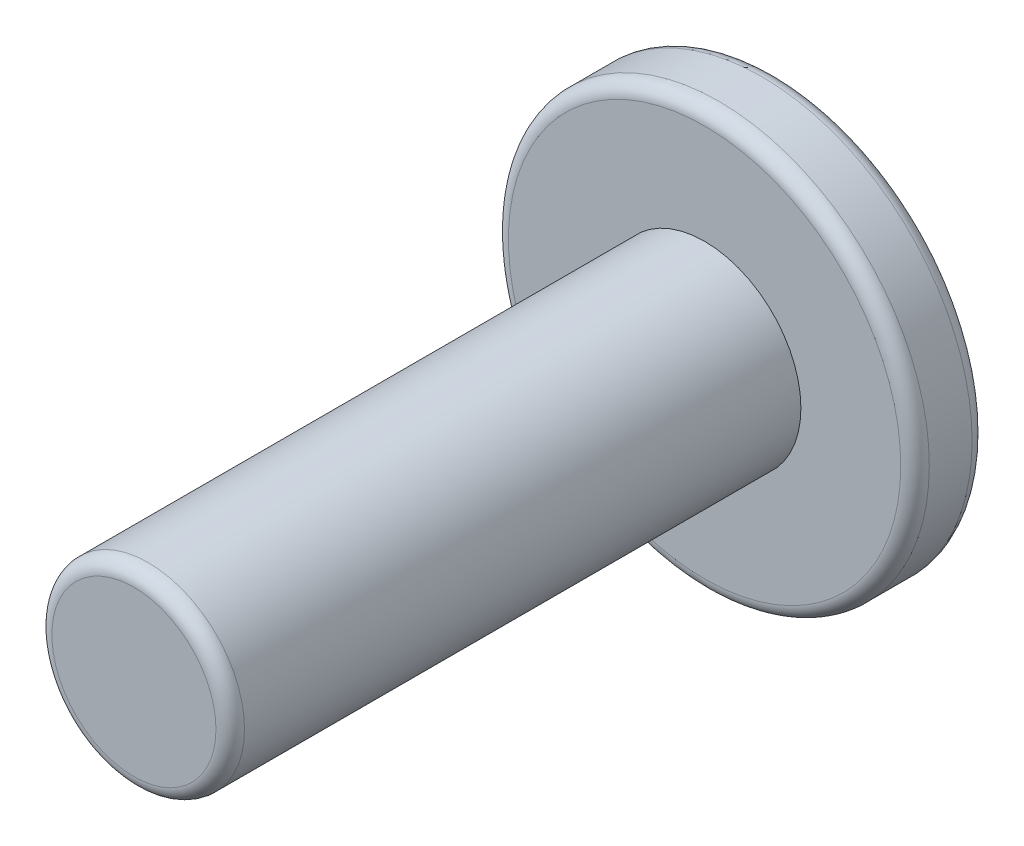
from build123d import *

# Parameters (mm, degrees)
SKETCH1_R           = 2.95
BOSS_EXTRUDE1_DEPTH = 1
SKETCH2_R           = 1.35
BOSS_EXTRUDE2_DEPTH = 8
FILLET1_R           = 0.2


with BuildPart() as part:
    # Sketch1 → Boss-Extrude1 (new body)
    with BuildSketch(Plane.XY):
        Circle(SKETCH1_R)
    extrude(amount=BOSS_EXTRUDE1_DEPTH)

    # Sketch2 → Boss-Extrude2 (add)
    with BuildSketch(Plane.XY.offset(1)):
        Circle(SKETCH2_R)
    extrude(amount=BOSS_EXTRUDE2_DEPTH)

    # Fillet1
    fillet1_edges = [part.edges().sort_by_distance(p)[0] for p in [
        (-2.95, 0, 0),
        (-2.95, 0, 1),
        (-1.35, 0, 9),
    ]]
    fillet(fillet1_edges, radius=FILLET1_R)


solid = part.part
